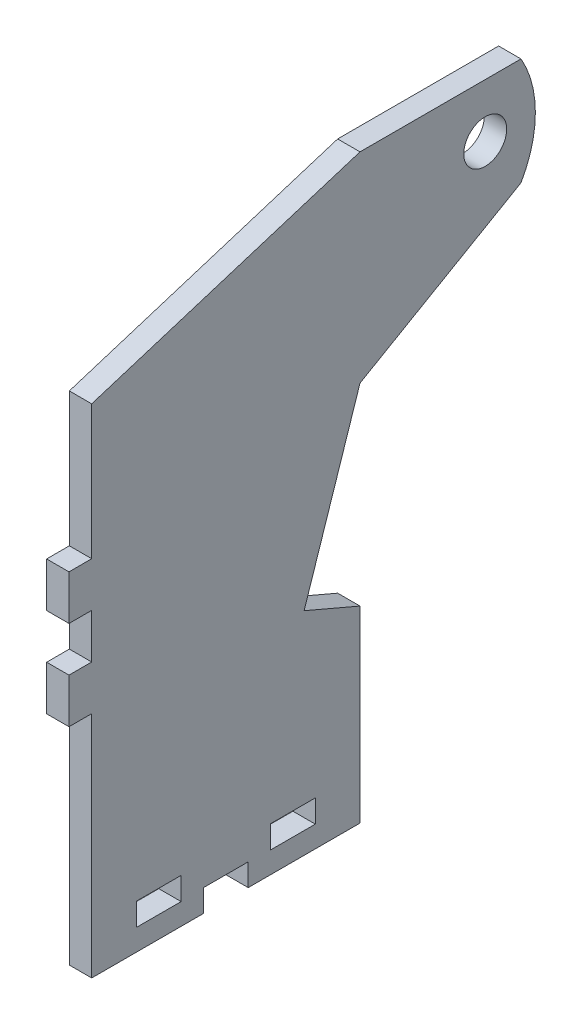
from build123d import *

# Parameters (mm, degrees)
BOSS_EXTRUDE1_DEPTH       = 3.175
SKETCH3_R                 = 3.048
CUT_FOR_AXLE_DEPTH        = 4.175
SKETCH4_W                 = 6.35
SKETCH4_H                 = 3.2258
CUT_FOR_TABS_DEPTH        = 4.175
CUT_FOR_CLEARANCE_DEPTH   = 4.175
CUT_EXTRUDE1_DEPTH        = 4.175
SKETCH10_W                = 3.2258
SKETCH10_H                = 6.35
TABS_FOR_BACK_PLATE_DEPTH = 3.175


with BuildPart() as part:
    # Sketch1 → Boss-Extrude1 (new body)
    with BuildSketch(Plane(origin=(0, 0, 0), x_dir=(0, 0, -1), z_dir=(1, 0, 0))):
        with BuildLine():
            Line((-8.901335672, 27.917328656), (29.198664328, 27.917328656))
            Line((29.198664328, 27.917328656), (52.058664328, 27.917328656))
            ThreePointArc((52.058664328, 27.917328656), (54.100437174, 20.297328656), (52.058664328, 12.677328656))
            Line((52.058664328, 12.677328656), (29.198664328, -0.520898498))
            Line((29.198664328, -0.520898498), (29.198664328, -54.632671344))
            Line((29.198664328, -54.632671344), (-8.901335672, -54.632671344))
            Line((-8.901335672, -54.632671344), (-8.901335672, 27.917328656))
        make_face()
    extrude(amount=BOSS_EXTRUDE1_DEPTH)

    # Sketch3 → cut for axle (cut, through all)
    with BuildSketch(Plane(origin=(3.175, 0, 0), x_dir=(0, 0, -1), z_dir=(1, 0, 0))):
        with Locations((46.978664328, 20.297328656)):
            Circle(SKETCH3_R)
    extrude(amount=-CUT_FOR_AXLE_DEPTH, mode=Mode.SUBTRACT)

    # Sketch4 → cut for tabs (cut, through all)
    with BuildSketch(Plane(origin=(3.175, 0, 0), x_dir=(0, 0, -1), z_dir=(1, 0, 0))):
        with Locations((0.623664328, -49.971771344)):
            Rectangle(SKETCH4_W, SKETCH4_H)
        with Locations((19.673664328, -49.971771344)):
            Rectangle(SKETCH4_W, SKETCH4_H)
        Polygon((10.148664328, -54.632671344), (6.973664328, -54.632671344), (6.973664328, -51.457671344), (13.323664328, -51.457671344), (13.323664328, -54.632671344), align=None)
    extrude(amount=-CUT_FOR_TABS_DEPTH, mode=Mode.SUBTRACT)

    # Sketch6 → cut for clearance (cut, through all)
    with BuildSketch(Plane(origin=(3.175, 0, 0), x_dir=(0, 0, -1), z_dir=(1, 0, 0))):
        Polygon((29.198664328, -0.520898498), (21.256966839, -24.543474446), (29.198664328, -27.939523247), align=None)
    extrude(amount=-CUT_FOR_CLEARANCE_DEPTH, mode=Mode.SUBTRACT)

    # Sketch9 → Cut-Extrude1 (cut, through all)
    with BuildSketch(Plane.ZY):
        Polygon((8.901335672, 27.917328656), (-29.198664328, 27.917328656), (8.901335672, 15.979328656), align=None)
    extrude(amount=-CUT_EXTRUDE1_DEPTH, mode=Mode.SUBTRACT)

    # Sketch10 → tabs for back plate (add)
    with BuildSketch(Plane.ZY):
        with Locations((10.514235672, -6.245671344)):
            Rectangle(SKETCH10_W, SKETCH10_H)
        with Locations((10.514235672, -18.945671344)):
            Rectangle(SKETCH10_W, SKETCH10_H)
    extrude(amount=-TABS_FOR_BACK_PLATE_DEPTH)


solid = part.part
